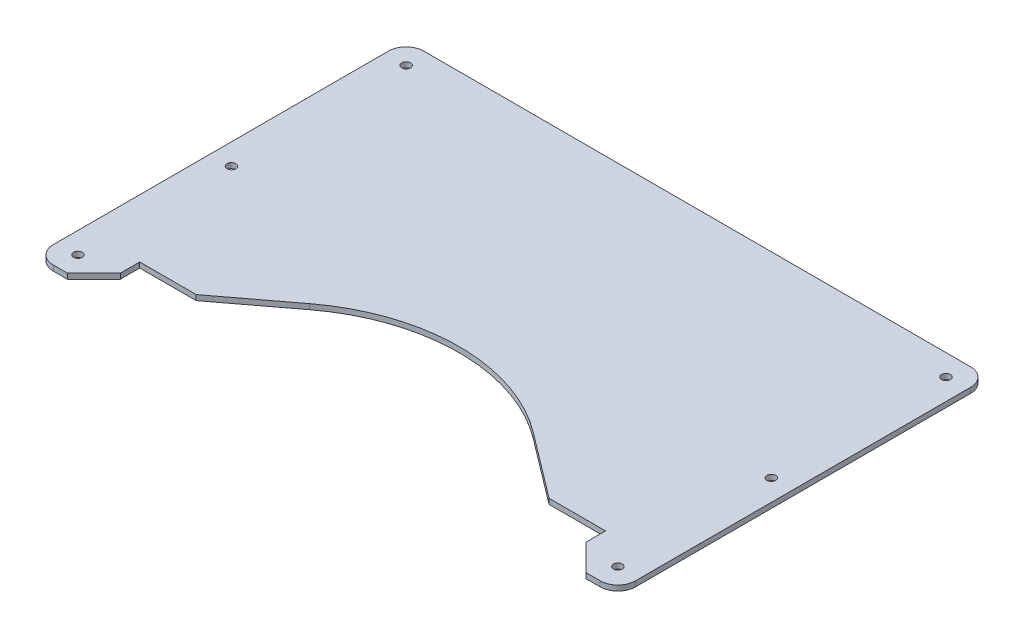
from build123d import *

# Parameters (mm, degrees)
ESQUISSE1_R      = 2.5
EXTRUSION1_DEPTH = 3
CONG_1_R         = 10


with BuildPart() as part:
    # Esquisse1 → Extrusion1 (new body)
    with BuildSketch(Plane(origin=(0, 0, 0), x_dir=(1, 0, 0), z_dir=(0, 1, 0))):
        with BuildLine():
            Line((165, 0), (-165, 0))
            Line((-165, 0), (-165, -210))
            Line((-165, -210), (-147, -210))
            Line((-147, -210), (-132, -195))
            Line((-132, -195), (-132, -184))
            Line((-132, -184), (-100, -184))
            Line((-100, -184), (-63.363257782, -156.27367461))
            ThreePointArc((-63.363257782, -156.27367461), (0, -135), (63.363257782, -156.27367461))
            Line((63.363257782, -156.27367461), (100, -184))
            Line((100, -184), (132, -184))
            Line((132, -184), (132, -195))
            Line((132, -195), (147, -210))
            Line((147, -210), (165, -210))
            Line((165, -210), (165, 0))
        make_face()
        with Locations((-153, -12)):
            Circle(ESQUISSE1_R, mode=Mode.SUBTRACT)
        with Locations((153, -12)):
            Circle(ESQUISSE1_R, mode=Mode.SUBTRACT)
        with Locations((-153, -198)):
            Circle(ESQUISSE1_R, mode=Mode.SUBTRACT)
        with Locations((153, -198)):
            Circle(ESQUISSE1_R, mode=Mode.SUBTRACT)
        with Locations((-153, -111)):
            Circle(ESQUISSE1_R, mode=Mode.SUBTRACT)
        with Locations((153, -111)):
            Circle(ESQUISSE1_R, mode=Mode.SUBTRACT)
    extrude(amount=EXTRUSION1_DEPTH)

    # Congé1
    cong_1_edges = [part.edges().sort_by_distance(p)[0] for p in [
        (-165, 1.5, 0),
        (165, 1.5, 0),
        (165, 1.5, 210),
        (-165, 1.5, 210),
    ]]
    fillet(cong_1_edges, radius=CONG_1_R)


solid = part.part
